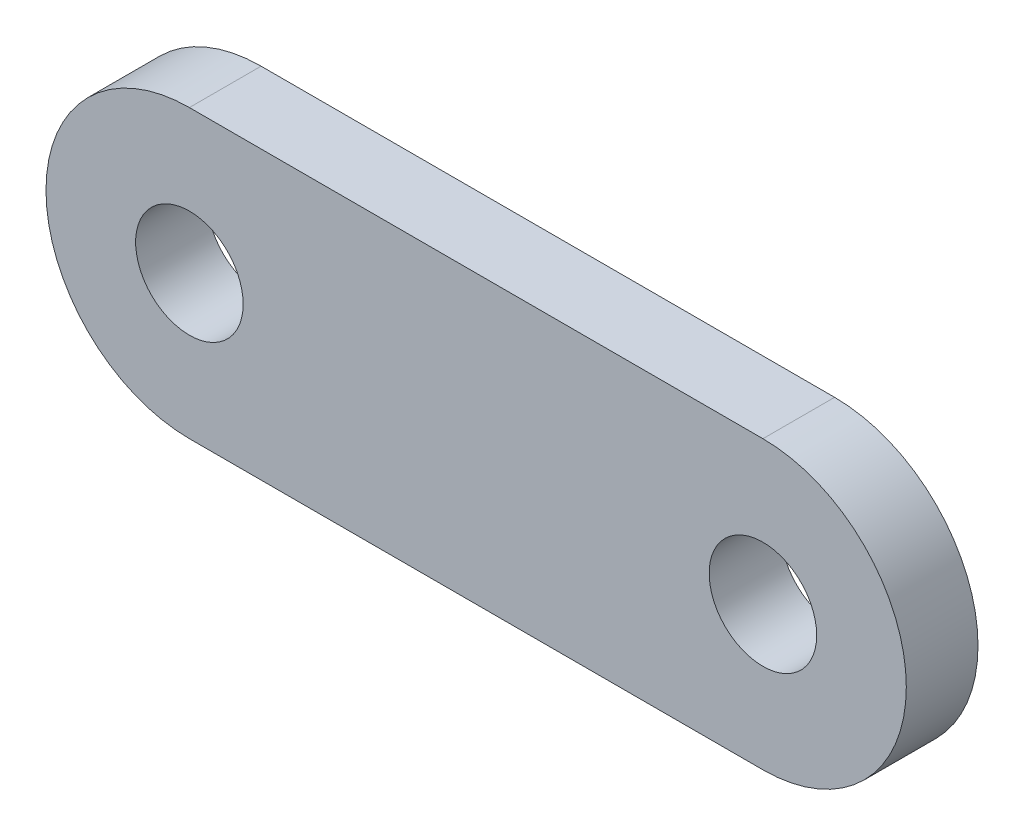
from build123d import *

# Parameters (mm, degrees)
SKETCH1_R           = 4.7625
BOSS_EXTRUDE1_DEPTH = 6.35


with BuildPart() as part:
    # Sketch1 → Boss-Extrude1 (new body)
    with BuildSketch(Plane.XY):
        with BuildLine():
            Line((-25.4, 12.7), (25.4, 12.7))
            ThreePointArc((25.4, 12.7), (38.1, 0), (25.4, -12.7))
            Line((25.4, -12.7), (-25.4, -12.7))
            ThreePointArc((-25.4, -12.7), (-38.1, 0), (-25.4, 12.7))
        make_face()
        with Locations((-25.4, 0)):
            Circle(SKETCH1_R, mode=Mode.SUBTRACT)
        with Locations((25.4, 0)):
            Circle(SKETCH1_R, mode=Mode.SUBTRACT)
    extrude(amount=BOSS_EXTRUDE1_DEPTH)


solid = part.part
